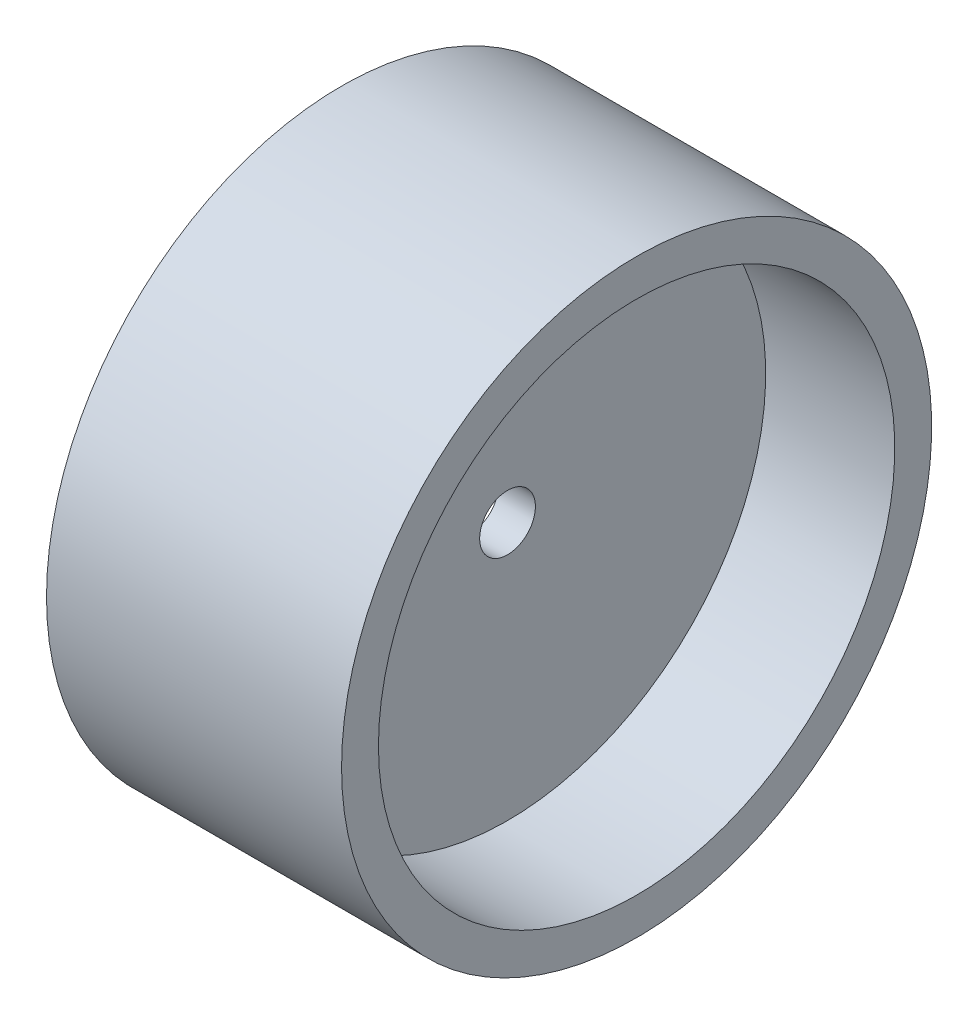
from build123d import *

# Parameters (mm, degrees)
SKETCH1_W            = 1.5875
SKETCH1_H            = 22.225
M4_CLEARANCE_HOLE1_D = 4.8


with BuildPart() as part:
    # Sketch1 → Revolve1 (revolve)
    with BuildSketch(Plane.XY):
        Polygon((0, 25.4), (0, 22.225), (1.5875, 22.225), (12.7, 22.225), (12.7, 25.4), align=None)
        Polygon((-1.5875, 22.225), (0, 22.225), (0, 25.4), (-12.7, 25.4), (-12.7, 22.225), align=None)
        with Locations((-0.79375, 11.1125)):
            Rectangle(SKETCH1_W, SKETCH1_H)
        with Locations((0.79375, 11.1125)):
            Rectangle(SKETCH1_W, SKETCH1_H)
    revolve(axis=Axis((0, 0, 0), (1, 0, 0)))

    # M4 Clearance Hole1 (through all)
    with Locations(Plane.ZY.offset(1.5875)):
        with Locations((0, 0)):
            Hole(M4_CLEARANCE_HOLE1_D / 2)


solid = part.part
